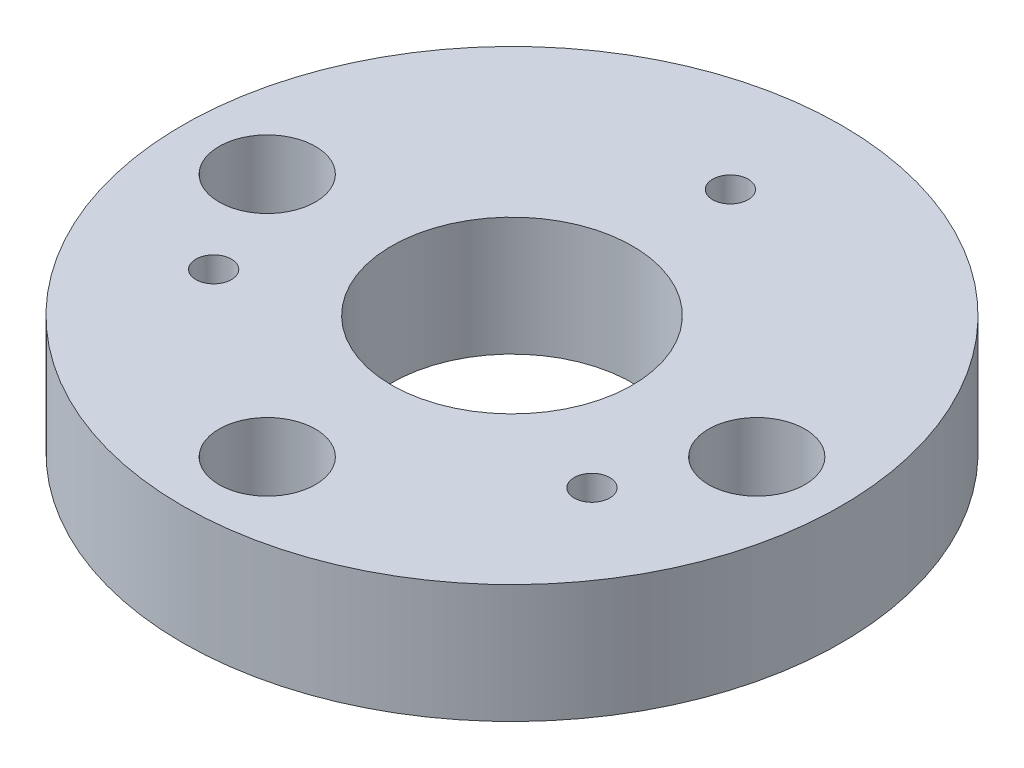
from build123d import *

# Parameters (mm, degrees)
SKETCH1_R               = 27.7876
SKETCH1_R_2             = 10.16
RING_DEPTH              = 10
SKETCH2_R               = 1.5
ROBOT_SIDE1_HOLES_DEPTH = 11
ROBOT_SIDE_CHAMFER_SIZE = 2.4
SKETCH3_R               = 1.838724863
TOOL_SIDE_HOLES_DEPTH   = 11
SKETCH4_R               = 4.064
TOOL_SIDE_INSET_DEPTH   = 6


with BuildPart() as part:
    # Sketch1 → Ring (new body)
    with BuildSketch(Plane(origin=(0, 0, 0), x_dir=(1, 0, 0), z_dir=(0, 1, 0))):
        Circle(SKETCH1_R)
        Circle(SKETCH1_R_2, mode=Mode.SUBTRACT)
    extrude(amount=RING_DEPTH)

    # Sketch2 → Robot Side1 - Holes (cut, through all)
    with BuildSketch(Plane(origin=(0, 10, 0), x_dir=(1, 0, 0), z_dir=(0, 1, 0))):
        with Locations((0, 18.415)):
            Circle(SKETCH2_R)
        with Locations((15.947857811, -9.2075)):
            Circle(SKETCH2_R)
        with Locations((-15.947857811, -9.2075)):
            Circle(SKETCH2_R)
    extrude(amount=-ROBOT_SIDE1_HOLES_DEPTH, mode=Mode.SUBTRACT)

    # Robot Side - Chamfer
    robot_side_chamfer_edges = [part.edges().sort_by_distance(p)[0] for p in [
        (-1.5, 0, -18.415),
        (14.447857811, 0, 9.2075),
        (-17.447857811, 0, 9.2075),
    ]]
    chamfer(robot_side_chamfer_edges, length=ROBOT_SIDE_CHAMFER_SIZE)

    # Sketch3 → Tool Side - Holes (cut, through all)
    with BuildSketch(Plane(origin=(0, 10, 0), x_dir=(1, 0, 0), z_dir=(0, 1, 0))):
        with Locations((20.6375, 0)):
            Circle(SKETCH3_R)
        with Locations((0, -20.6375)):
            Circle(SKETCH3_R)
        with Locations((-20.6375, 0)):
            Circle(SKETCH3_R)
    extrude(amount=-TOOL_SIDE_HOLES_DEPTH, mode=Mode.SUBTRACT)

    # Sketch4 → Tool Side - Inset (cut)
    with BuildSketch(Plane(origin=(0, 10, 0), x_dir=(1, 0, 0), z_dir=(0, 1, 0))):
        with Locations((-20.6375, 0)):
            Circle(SKETCH4_R)
        with Locations((0, -20.6375)):
            Circle(SKETCH4_R)
        with Locations((20.6375, 0)):
            Circle(SKETCH4_R)
    extrude(amount=-TOOL_SIDE_INSET_DEPTH, mode=Mode.SUBTRACT)


solid = part.part
